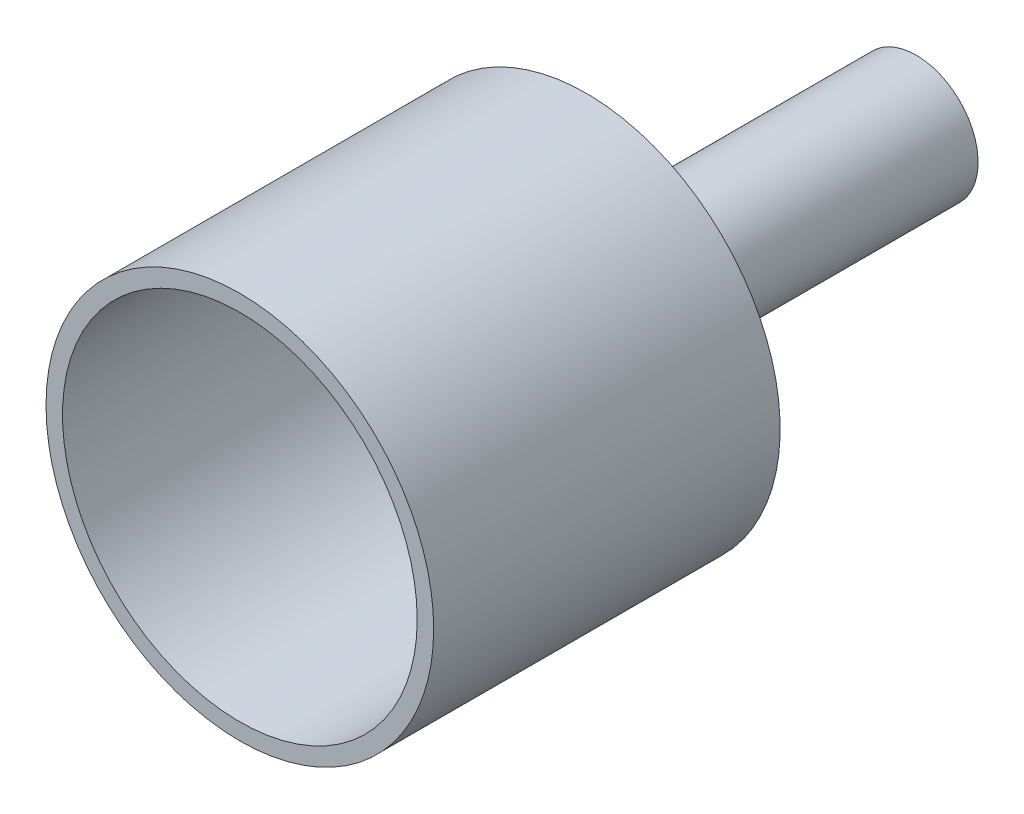
from build123d import *

# Parameters (mm, degrees)
SKETCH1_R               = 23.5
SKETCH1_R_2             = 21.5
BOSS_EXTRUDE1_DEPTH     = 40
SKETCH3_R               = 23.5
BOSS_EXTRUDE4_DEPTH     = 2
SKETCH4_R               = 7.5
SKETCH4_R_2             = 5.5
BOSS_EXTRUDE5_DEPTH     = 40
SKETCH5_R               = 5.5
CUT_EXTRUDE1_DEPTH      = 41
CUT_EXTRUDE1_DEPTH_BACK = 43


with BuildPart() as part:
    # Sketch1 → Boss-Extrude1 (new body)
    with BuildSketch(Plane.XY):
        Circle(SKETCH1_R)
        Circle(SKETCH1_R_2, mode=Mode.SUBTRACT)
    extrude(amount=BOSS_EXTRUDE1_DEPTH)

    # Sketch3 → Boss-Extrude4 (add)
    with BuildSketch(Plane(origin=(0, 0, 0), x_dir=(-1, 0, 0), z_dir=(0, 0, -1))):
        Circle(SKETCH3_R)
    extrude(amount=BOSS_EXTRUDE4_DEPTH)

    # Sketch4 → Boss-Extrude5 (add)
    with BuildSketch(Plane(origin=(0, 0, -2), x_dir=(-1, 0, 0), z_dir=(0, 0, -1))):
        Circle(SKETCH4_R)
        Circle(SKETCH4_R_2, mode=Mode.SUBTRACT)
    extrude(amount=BOSS_EXTRUDE5_DEPTH)

    # Sketch5 → Cut-Extrude1 (cut, two sides)
    with BuildSketch(Plane(origin=(0, 0, -2), x_dir=(-1, 0, 0), z_dir=(0, 0, -1))) as cut_extrude1_sk:
        Circle(SKETCH5_R)
    extrude(amount=CUT_EXTRUDE1_DEPTH, mode=Mode.SUBTRACT)
    extrude(cut_extrude1_sk.sketch, amount=-CUT_EXTRUDE1_DEPTH_BACK, mode=Mode.SUBTRACT)


solid = part.part
